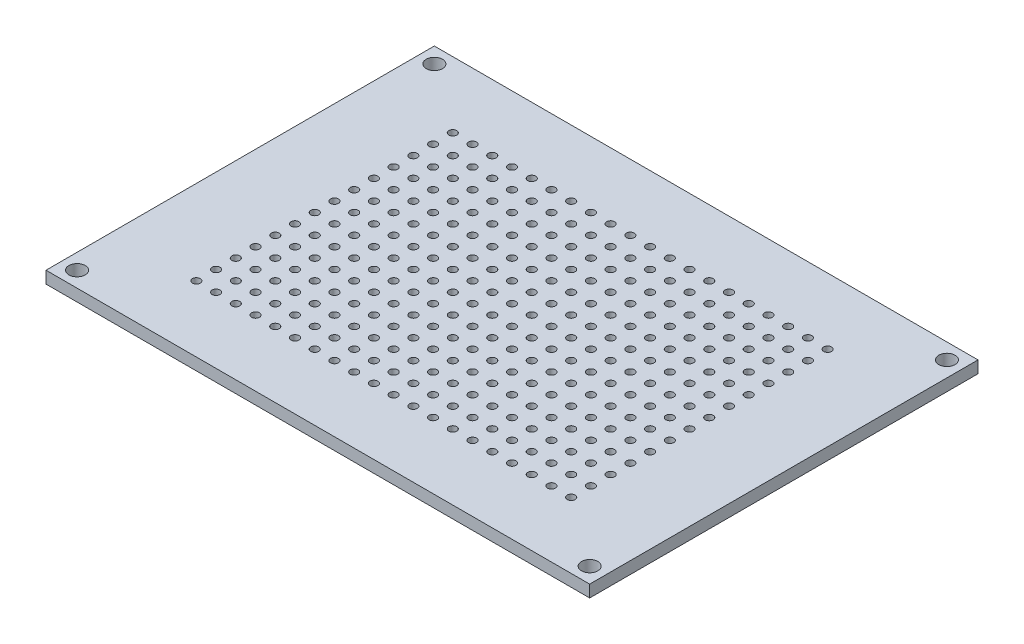
from build123d import *

# Parameters (mm, degrees)
SKETCH1_W           = 70
SKETCH1_H           = 50
SKETCH1_R           = 0.508
SKETCH1_R_2         = 1.05
BOSS_EXTRUDE1_DEPTH = 1.55


with BuildPart() as part:
    # Sketch1 → Boss-Extrude1 (new body)
    with BuildSketch(Plane(origin=(0, 0, 0), x_dir=(1, 0, 0), z_dir=(0, 1, 0))):
        with Locations((35, 25)):
            Rectangle(SKETCH1_W, SKETCH1_H)
        with Locations((33.73, 23.73)):
            Circle(SKETCH1_R, mode=Mode.SUBTRACT)
        with Locations((36.27, 23.73)):
            Circle(SKETCH1_R, mode=Mode.SUBTRACT)
        with Locations((38.81, 23.73)):
            Circle(SKETCH1_R, mode=Mode.SUBTRACT)
        with Locations((41.35, 23.73)):
            Circle(SKETCH1_R, mode=Mode.SUBTRACT)
        with Locations((43.89, 23.73)):
            Circle(SKETCH1_R, mode=Mode.SUBTRACT)
        with Locations((46.43, 23.73)):
            Circle(SKETCH1_R, mode=Mode.SUBTRACT)
        with Locations((48.97, 23.73)):
            Circle(SKETCH1_R, mode=Mode.SUBTRACT)
        with Locations((51.51, 23.73)):
            Circle(SKETCH1_R, mode=Mode.SUBTRACT)
        with Locations((54.05, 23.73)):
            Circle(SKETCH1_R, mode=Mode.SUBTRACT)
        with Locations((56.59, 23.73)):
            Circle(SKETCH1_R, mode=Mode.SUBTRACT)
        with Locations((59.13, 23.73)):
            Circle(SKETCH1_R, mode=Mode.SUBTRACT)
        with Locations((36.27, 26.27)):
            Circle(SKETCH1_R, mode=Mode.SUBTRACT)
        with Locations((38.81, 26.27)):
            Circle(SKETCH1_R, mode=Mode.SUBTRACT)
        with Locations((41.35, 26.27)):
            Circle(SKETCH1_R, mode=Mode.SUBTRACT)
        with Locations((43.89, 26.27)):
            Circle(SKETCH1_R, mode=Mode.SUBTRACT)
        with Locations((46.43, 26.27)):
            Circle(SKETCH1_R, mode=Mode.SUBTRACT)
        with Locations((48.97, 26.27)):
            Circle(SKETCH1_R, mode=Mode.SUBTRACT)
        with Locations((51.51, 26.27)):
            Circle(SKETCH1_R, mode=Mode.SUBTRACT)
        with Locations((54.05, 26.27)):
            Circle(SKETCH1_R, mode=Mode.SUBTRACT)
        with Locations((56.59, 26.27)):
            Circle(SKETCH1_R, mode=Mode.SUBTRACT)
        with Locations((59.13, 26.27)):
            Circle(SKETCH1_R, mode=Mode.SUBTRACT)
        with Locations((36.27, 28.81)):
            Circle(SKETCH1_R, mode=Mode.SUBTRACT)
        with Locations((38.81, 28.81)):
            Circle(SKETCH1_R, mode=Mode.SUBTRACT)
        with Locations((41.35, 28.81)):
            Circle(SKETCH1_R, mode=Mode.SUBTRACT)
        with Locations((43.89, 28.81)):
            Circle(SKETCH1_R, mode=Mode.SUBTRACT)
        with Locations((46.43, 28.81)):
            Circle(SKETCH1_R, mode=Mode.SUBTRACT)
        with Locations((48.97, 28.81)):
            Circle(SKETCH1_R, mode=Mode.SUBTRACT)
        with Locations((51.51, 28.81)):
            Circle(SKETCH1_R, mode=Mode.SUBTRACT)
        with Locations((54.05, 28.81)):
            Circle(SKETCH1_R, mode=Mode.SUBTRACT)
        with Locations((56.59, 28.81)):
            Circle(SKETCH1_R, mode=Mode.SUBTRACT)
        with Locations((59.13, 28.81)):
            Circle(SKETCH1_R, mode=Mode.SUBTRACT)
        with Locations((36.27, 31.35)):
            Circle(SKETCH1_R, mode=Mode.SUBTRACT)
        with Locations((38.81, 31.35)):
            Circle(SKETCH1_R, mode=Mode.SUBTRACT)
        with Locations((41.35, 31.35)):
            Circle(SKETCH1_R, mode=Mode.SUBTRACT)
        with Locations((43.89, 31.35)):
            Circle(SKETCH1_R, mode=Mode.SUBTRACT)
        with Locations((46.43, 31.35)):
            Circle(SKETCH1_R, mode=Mode.SUBTRACT)
        with Locations((48.97, 31.35)):
            Circle(SKETCH1_R, mode=Mode.SUBTRACT)
        with Locations((51.51, 31.35)):
            Circle(SKETCH1_R, mode=Mode.SUBTRACT)
        with Locations((54.05, 31.35)):
            Circle(SKETCH1_R, mode=Mode.SUBTRACT)
        with Locations((56.59, 31.35)):
            Circle(SKETCH1_R, mode=Mode.SUBTRACT)
        with Locations((59.13, 31.35)):
            Circle(SKETCH1_R, mode=Mode.SUBTRACT)
        with Locations((36.27, 33.89)):
            Circle(SKETCH1_R, mode=Mode.SUBTRACT)
        with Locations((38.81, 33.89)):
            Circle(SKETCH1_R, mode=Mode.SUBTRACT)
        with Locations((41.35, 33.89)):
            Circle(SKETCH1_R, mode=Mode.SUBTRACT)
        with Locations((43.89, 33.89)):
            Circle(SKETCH1_R, mode=Mode.SUBTRACT)
        with Locations((46.43, 33.89)):
            Circle(SKETCH1_R, mode=Mode.SUBTRACT)
        with Locations((48.97, 33.89)):
            Circle(SKETCH1_R, mode=Mode.SUBTRACT)
        with Locations((51.51, 33.89)):
            Circle(SKETCH1_R, mode=Mode.SUBTRACT)
        with Locations((54.05, 33.89)):
            Circle(SKETCH1_R, mode=Mode.SUBTRACT)
        with Locations((56.59, 33.89)):
            Circle(SKETCH1_R, mode=Mode.SUBTRACT)
        with Locations((59.13, 33.89)):
            Circle(SKETCH1_R, mode=Mode.SUBTRACT)
        with Locations((36.27, 36.43)):
            Circle(SKETCH1_R, mode=Mode.SUBTRACT)
        with Locations((38.81, 36.43)):
            Circle(SKETCH1_R, mode=Mode.SUBTRACT)
        with Locations((41.35, 36.43)):
            Circle(SKETCH1_R, mode=Mode.SUBTRACT)
        with Locations((43.89, 36.43)):
            Circle(SKETCH1_R, mode=Mode.SUBTRACT)
        with Locations((46.43, 36.43)):
            Circle(SKETCH1_R, mode=Mode.SUBTRACT)
        with Locations((48.97, 36.43)):
            Circle(SKETCH1_R, mode=Mode.SUBTRACT)
        with Locations((51.51, 36.43)):
            Circle(SKETCH1_R, mode=Mode.SUBTRACT)
        with Locations((54.05, 36.43)):
            Circle(SKETCH1_R, mode=Mode.SUBTRACT)
        with Locations((56.59, 36.43)):
            Circle(SKETCH1_R, mode=Mode.SUBTRACT)
        with Locations((59.13, 36.43)):
            Circle(SKETCH1_R, mode=Mode.SUBTRACT)
        with Locations((36.27, 38.97)):
            Circle(SKETCH1_R, mode=Mode.SUBTRACT)
        with Locations((38.81, 38.97)):
            Circle(SKETCH1_R, mode=Mode.SUBTRACT)
        with Locations((41.35, 38.97)):
            Circle(SKETCH1_R, mode=Mode.SUBTRACT)
        with Locations((43.89, 38.97)):
            Circle(SKETCH1_R, mode=Mode.SUBTRACT)
        with Locations((46.43, 38.97)):
            Circle(SKETCH1_R, mode=Mode.SUBTRACT)
        with Locations((48.97, 38.97)):
            Circle(SKETCH1_R, mode=Mode.SUBTRACT)
        with Locations((51.51, 38.97)):
            Circle(SKETCH1_R, mode=Mode.SUBTRACT)
        with Locations((54.05, 38.97)):
            Circle(SKETCH1_R, mode=Mode.SUBTRACT)
        with Locations((56.59, 38.97)):
            Circle(SKETCH1_R, mode=Mode.SUBTRACT)
        with Locations((59.13, 38.97)):
            Circle(SKETCH1_R, mode=Mode.SUBTRACT)
        with Locations((36.27, 41.51)):
            Circle(SKETCH1_R, mode=Mode.SUBTRACT)
        with Locations((38.81, 41.51)):
            Circle(SKETCH1_R, mode=Mode.SUBTRACT)
        with Locations((41.35, 41.51)):
            Circle(SKETCH1_R, mode=Mode.SUBTRACT)
        with Locations((43.89, 41.51)):
            Circle(SKETCH1_R, mode=Mode.SUBTRACT)
        with Locations((46.43, 41.51)):
            Circle(SKETCH1_R, mode=Mode.SUBTRACT)
        with Locations((48.97, 41.51)):
            Circle(SKETCH1_R, mode=Mode.SUBTRACT)
        with Locations((51.51, 41.51)):
            Circle(SKETCH1_R, mode=Mode.SUBTRACT)
        with Locations((54.05, 41.51)):
            Circle(SKETCH1_R, mode=Mode.SUBTRACT)
        with Locations((56.59, 41.51)):
            Circle(SKETCH1_R, mode=Mode.SUBTRACT)
        with Locations((59.13, 41.51)):
            Circle(SKETCH1_R, mode=Mode.SUBTRACT)
        with Locations((33.73, 26.27)):
            Circle(SKETCH1_R, mode=Mode.SUBTRACT)
        with Locations((33.73, 28.81)):
            Circle(SKETCH1_R, mode=Mode.SUBTRACT)
        with Locations((33.73, 31.35)):
            Circle(SKETCH1_R, mode=Mode.SUBTRACT)
        with Locations((33.73, 33.89)):
            Circle(SKETCH1_R, mode=Mode.SUBTRACT)
        with Locations((33.73, 36.43)):
            Circle(SKETCH1_R, mode=Mode.SUBTRACT)
        with Locations((33.73, 38.97)):
            Circle(SKETCH1_R, mode=Mode.SUBTRACT)
        with Locations((33.73, 41.51)):
            Circle(SKETCH1_R, mode=Mode.SUBTRACT)
        with Locations((31.19, 41.51)):
            Circle(SKETCH1_R, mode=Mode.SUBTRACT)
        with Locations((28.65, 41.51)):
            Circle(SKETCH1_R, mode=Mode.SUBTRACT)
        with Locations((26.11, 41.51)):
            Circle(SKETCH1_R, mode=Mode.SUBTRACT)
        with Locations((23.57, 41.51)):
            Circle(SKETCH1_R, mode=Mode.SUBTRACT)
        with Locations((21.03, 41.51)):
            Circle(SKETCH1_R, mode=Mode.SUBTRACT)
        with Locations((18.49, 41.51)):
            Circle(SKETCH1_R, mode=Mode.SUBTRACT)
        with Locations((15.95, 41.51)):
            Circle(SKETCH1_R, mode=Mode.SUBTRACT)
        with Locations((13.41, 41.51)):
            Circle(SKETCH1_R, mode=Mode.SUBTRACT)
        with Locations((10.87, 41.51)):
            Circle(SKETCH1_R, mode=Mode.SUBTRACT)
        with Locations((31.19, 38.97)):
            Circle(SKETCH1_R, mode=Mode.SUBTRACT)
        with Locations((28.65, 38.97)):
            Circle(SKETCH1_R, mode=Mode.SUBTRACT)
        with Locations((26.11, 38.97)):
            Circle(SKETCH1_R, mode=Mode.SUBTRACT)
        with Locations((23.57, 38.97)):
            Circle(SKETCH1_R, mode=Mode.SUBTRACT)
        with Locations((21.03, 38.97)):
            Circle(SKETCH1_R, mode=Mode.SUBTRACT)
        with Locations((18.49, 38.97)):
            Circle(SKETCH1_R, mode=Mode.SUBTRACT)
        with Locations((15.95, 38.97)):
            Circle(SKETCH1_R, mode=Mode.SUBTRACT)
        with Locations((13.41, 38.97)):
            Circle(SKETCH1_R, mode=Mode.SUBTRACT)
        with Locations((10.87, 38.97)):
            Circle(SKETCH1_R, mode=Mode.SUBTRACT)
        with Locations((31.19, 36.43)):
            Circle(SKETCH1_R, mode=Mode.SUBTRACT)
        with Locations((28.65, 36.43)):
            Circle(SKETCH1_R, mode=Mode.SUBTRACT)
        with Locations((26.11, 36.43)):
            Circle(SKETCH1_R, mode=Mode.SUBTRACT)
        with Locations((23.57, 36.43)):
            Circle(SKETCH1_R, mode=Mode.SUBTRACT)
        with Locations((21.03, 36.43)):
            Circle(SKETCH1_R, mode=Mode.SUBTRACT)
        with Locations((18.49, 36.43)):
            Circle(SKETCH1_R, mode=Mode.SUBTRACT)
        with Locations((15.95, 36.43)):
            Circle(SKETCH1_R, mode=Mode.SUBTRACT)
        with Locations((13.41, 36.43)):
            Circle(SKETCH1_R, mode=Mode.SUBTRACT)
        with Locations((10.87, 36.43)):
            Circle(SKETCH1_R, mode=Mode.SUBTRACT)
        with Locations((31.19, 33.89)):
            Circle(SKETCH1_R, mode=Mode.SUBTRACT)
        with Locations((28.65, 33.89)):
            Circle(SKETCH1_R, mode=Mode.SUBTRACT)
        with Locations((26.11, 33.89)):
            Circle(SKETCH1_R, mode=Mode.SUBTRACT)
        with Locations((23.57, 33.89)):
            Circle(SKETCH1_R, mode=Mode.SUBTRACT)
        with Locations((21.03, 33.89)):
            Circle(SKETCH1_R, mode=Mode.SUBTRACT)
        with Locations((18.49, 33.89)):
            Circle(SKETCH1_R, mode=Mode.SUBTRACT)
        with Locations((15.95, 33.89)):
            Circle(SKETCH1_R, mode=Mode.SUBTRACT)
        with Locations((13.41, 33.89)):
            Circle(SKETCH1_R, mode=Mode.SUBTRACT)
        with Locations((10.87, 33.89)):
            Circle(SKETCH1_R, mode=Mode.SUBTRACT)
        with Locations((31.19, 31.35)):
            Circle(SKETCH1_R, mode=Mode.SUBTRACT)
        with Locations((28.65, 31.35)):
            Circle(SKETCH1_R, mode=Mode.SUBTRACT)
        with Locations((26.11, 31.35)):
            Circle(SKETCH1_R, mode=Mode.SUBTRACT)
        with Locations((23.57, 31.35)):
            Circle(SKETCH1_R, mode=Mode.SUBTRACT)
        with Locations((21.03, 31.35)):
            Circle(SKETCH1_R, mode=Mode.SUBTRACT)
        with Locations((18.49, 31.35)):
            Circle(SKETCH1_R, mode=Mode.SUBTRACT)
        with Locations((15.95, 31.35)):
            Circle(SKETCH1_R, mode=Mode.SUBTRACT)
        with Locations((13.41, 31.35)):
            Circle(SKETCH1_R, mode=Mode.SUBTRACT)
        with Locations((10.87, 31.35)):
            Circle(SKETCH1_R, mode=Mode.SUBTRACT)
        with Locations((31.19, 28.81)):
            Circle(SKETCH1_R, mode=Mode.SUBTRACT)
        with Locations((28.65, 28.81)):
            Circle(SKETCH1_R, mode=Mode.SUBTRACT)
        with Locations((26.11, 28.81)):
            Circle(SKETCH1_R, mode=Mode.SUBTRACT)
        with Locations((23.57, 28.81)):
            Circle(SKETCH1_R, mode=Mode.SUBTRACT)
        with Locations((21.03, 28.81)):
            Circle(SKETCH1_R, mode=Mode.SUBTRACT)
        with Locations((18.49, 28.81)):
            Circle(SKETCH1_R, mode=Mode.SUBTRACT)
        with Locations((15.95, 28.81)):
            Circle(SKETCH1_R, mode=Mode.SUBTRACT)
        with Locations((13.41, 28.81)):
            Circle(SKETCH1_R, mode=Mode.SUBTRACT)
        with Locations((10.87, 28.81)):
            Circle(SKETCH1_R, mode=Mode.SUBTRACT)
        with Locations((31.19, 26.27)):
            Circle(SKETCH1_R, mode=Mode.SUBTRACT)
        with Locations((28.65, 26.27)):
            Circle(SKETCH1_R, mode=Mode.SUBTRACT)
        with Locations((26.11, 26.27)):
            Circle(SKETCH1_R, mode=Mode.SUBTRACT)
        with Locations((23.57, 26.27)):
            Circle(SKETCH1_R, mode=Mode.SUBTRACT)
        with Locations((21.03, 26.27)):
            Circle(SKETCH1_R, mode=Mode.SUBTRACT)
        with Locations((18.49, 26.27)):
            Circle(SKETCH1_R, mode=Mode.SUBTRACT)
        with Locations((15.95, 26.27)):
            Circle(SKETCH1_R, mode=Mode.SUBTRACT)
        with Locations((13.41, 26.27)):
            Circle(SKETCH1_R, mode=Mode.SUBTRACT)
        with Locations((10.87, 26.27)):
            Circle(SKETCH1_R, mode=Mode.SUBTRACT)
        with Locations((31.19, 23.73)):
            Circle(SKETCH1_R, mode=Mode.SUBTRACT)
        with Locations((28.65, 23.73)):
            Circle(SKETCH1_R, mode=Mode.SUBTRACT)
        with Locations((26.11, 23.73)):
            Circle(SKETCH1_R, mode=Mode.SUBTRACT)
        with Locations((23.57, 23.73)):
            Circle(SKETCH1_R, mode=Mode.SUBTRACT)
        with Locations((21.03, 23.73)):
            Circle(SKETCH1_R, mode=Mode.SUBTRACT)
        with Locations((18.49, 23.73)):
            Circle(SKETCH1_R, mode=Mode.SUBTRACT)
        with Locations((15.95, 23.73)):
            Circle(SKETCH1_R, mode=Mode.SUBTRACT)
        with Locations((13.41, 23.73)):
            Circle(SKETCH1_R, mode=Mode.SUBTRACT)
        with Locations((10.87, 23.73)):
            Circle(SKETCH1_R, mode=Mode.SUBTRACT)
        with Locations((56.59, 21.19)):
            Circle(SKETCH1_R, mode=Mode.SUBTRACT)
        with Locations((54.05, 21.19)):
            Circle(SKETCH1_R, mode=Mode.SUBTRACT)
        with Locations((51.51, 21.19)):
            Circle(SKETCH1_R, mode=Mode.SUBTRACT)
        with Locations((48.97, 21.19)):
            Circle(SKETCH1_R, mode=Mode.SUBTRACT)
        with Locations((46.43, 21.19)):
            Circle(SKETCH1_R, mode=Mode.SUBTRACT)
        with Locations((43.89, 21.19)):
            Circle(SKETCH1_R, mode=Mode.SUBTRACT)
        with Locations((41.35, 21.19)):
            Circle(SKETCH1_R, mode=Mode.SUBTRACT)
        with Locations((38.81, 21.19)):
            Circle(SKETCH1_R, mode=Mode.SUBTRACT)
        with Locations((36.27, 21.19)):
            Circle(SKETCH1_R, mode=Mode.SUBTRACT)
        with Locations((33.73, 21.19)):
            Circle(SKETCH1_R, mode=Mode.SUBTRACT)
        with Locations((31.19, 21.19)):
            Circle(SKETCH1_R, mode=Mode.SUBTRACT)
        with Locations((28.65, 21.19)):
            Circle(SKETCH1_R, mode=Mode.SUBTRACT)
        with Locations((26.11, 21.19)):
            Circle(SKETCH1_R, mode=Mode.SUBTRACT)
        with Locations((23.57, 21.19)):
            Circle(SKETCH1_R, mode=Mode.SUBTRACT)
        with Locations((21.03, 21.19)):
            Circle(SKETCH1_R, mode=Mode.SUBTRACT)
        with Locations((18.49, 21.19)):
            Circle(SKETCH1_R, mode=Mode.SUBTRACT)
        with Locations((15.95, 21.19)):
            Circle(SKETCH1_R, mode=Mode.SUBTRACT)
        with Locations((13.41, 21.19)):
            Circle(SKETCH1_R, mode=Mode.SUBTRACT)
        with Locations((10.87, 21.19)):
            Circle(SKETCH1_R, mode=Mode.SUBTRACT)
        with Locations((56.59, 18.65)):
            Circle(SKETCH1_R, mode=Mode.SUBTRACT)
        with Locations((54.05, 18.65)):
            Circle(SKETCH1_R, mode=Mode.SUBTRACT)
        with Locations((51.51, 18.65)):
            Circle(SKETCH1_R, mode=Mode.SUBTRACT)
        with Locations((48.97, 18.65)):
            Circle(SKETCH1_R, mode=Mode.SUBTRACT)
        with Locations((46.43, 18.65)):
            Circle(SKETCH1_R, mode=Mode.SUBTRACT)
        with Locations((43.89, 18.65)):
            Circle(SKETCH1_R, mode=Mode.SUBTRACT)
        with Locations((41.35, 18.65)):
            Circle(SKETCH1_R, mode=Mode.SUBTRACT)
        with Locations((38.81, 18.65)):
            Circle(SKETCH1_R, mode=Mode.SUBTRACT)
        with Locations((36.27, 18.65)):
            Circle(SKETCH1_R, mode=Mode.SUBTRACT)
        with Locations((33.73, 18.65)):
            Circle(SKETCH1_R, mode=Mode.SUBTRACT)
        with Locations((31.19, 18.65)):
            Circle(SKETCH1_R, mode=Mode.SUBTRACT)
        with Locations((28.65, 18.65)):
            Circle(SKETCH1_R, mode=Mode.SUBTRACT)
        with Locations((26.11, 18.65)):
            Circle(SKETCH1_R, mode=Mode.SUBTRACT)
        with Locations((23.57, 18.65)):
            Circle(SKETCH1_R, mode=Mode.SUBTRACT)
        with Locations((21.03, 18.65)):
            Circle(SKETCH1_R, mode=Mode.SUBTRACT)
        with Locations((18.49, 18.65)):
            Circle(SKETCH1_R, mode=Mode.SUBTRACT)
        with Locations((15.95, 18.65)):
            Circle(SKETCH1_R, mode=Mode.SUBTRACT)
        with Locations((13.41, 18.65)):
            Circle(SKETCH1_R, mode=Mode.SUBTRACT)
        with Locations((10.87, 18.65)):
            Circle(SKETCH1_R, mode=Mode.SUBTRACT)
        with Locations((56.59, 16.11)):
            Circle(SKETCH1_R, mode=Mode.SUBTRACT)
        with Locations((54.05, 16.11)):
            Circle(SKETCH1_R, mode=Mode.SUBTRACT)
        with Locations((51.51, 16.11)):
            Circle(SKETCH1_R, mode=Mode.SUBTRACT)
        with Locations((48.97, 16.11)):
            Circle(SKETCH1_R, mode=Mode.SUBTRACT)
        with Locations((46.43, 16.11)):
            Circle(SKETCH1_R, mode=Mode.SUBTRACT)
        with Locations((43.89, 16.11)):
            Circle(SKETCH1_R, mode=Mode.SUBTRACT)
        with Locations((41.35, 16.11)):
            Circle(SKETCH1_R, mode=Mode.SUBTRACT)
        with Locations((38.81, 16.11)):
            Circle(SKETCH1_R, mode=Mode.SUBTRACT)
        with Locations((36.27, 16.11)):
            Circle(SKETCH1_R, mode=Mode.SUBTRACT)
        with Locations((33.73, 16.11)):
            Circle(SKETCH1_R, mode=Mode.SUBTRACT)
        with Locations((31.19, 16.11)):
            Circle(SKETCH1_R, mode=Mode.SUBTRACT)
        with Locations((28.65, 16.11)):
            Circle(SKETCH1_R, mode=Mode.SUBTRACT)
        with Locations((26.11, 16.11)):
            Circle(SKETCH1_R, mode=Mode.SUBTRACT)
        with Locations((23.57, 16.11)):
            Circle(SKETCH1_R, mode=Mode.SUBTRACT)
        with Locations((21.03, 16.11)):
            Circle(SKETCH1_R, mode=Mode.SUBTRACT)
        with Locations((18.49, 16.11)):
            Circle(SKETCH1_R, mode=Mode.SUBTRACT)
        with Locations((15.95, 16.11)):
            Circle(SKETCH1_R, mode=Mode.SUBTRACT)
        with Locations((13.41, 16.11)):
            Circle(SKETCH1_R, mode=Mode.SUBTRACT)
        with Locations((10.87, 16.11)):
            Circle(SKETCH1_R, mode=Mode.SUBTRACT)
        with Locations((56.59, 13.57)):
            Circle(SKETCH1_R, mode=Mode.SUBTRACT)
        with Locations((54.05, 13.57)):
            Circle(SKETCH1_R, mode=Mode.SUBTRACT)
        with Locations((51.51, 13.57)):
            Circle(SKETCH1_R, mode=Mode.SUBTRACT)
        with Locations((48.97, 13.57)):
            Circle(SKETCH1_R, mode=Mode.SUBTRACT)
        with Locations((46.43, 13.57)):
            Circle(SKETCH1_R, mode=Mode.SUBTRACT)
        with Locations((43.89, 13.57)):
            Circle(SKETCH1_R, mode=Mode.SUBTRACT)
        with Locations((41.35, 13.57)):
            Circle(SKETCH1_R, mode=Mode.SUBTRACT)
        with Locations((38.81, 13.57)):
            Circle(SKETCH1_R, mode=Mode.SUBTRACT)
        with Locations((36.27, 13.57)):
            Circle(SKETCH1_R, mode=Mode.SUBTRACT)
        with Locations((33.73, 13.57)):
            Circle(SKETCH1_R, mode=Mode.SUBTRACT)
        with Locations((31.19, 13.57)):
            Circle(SKETCH1_R, mode=Mode.SUBTRACT)
        with Locations((28.65, 13.57)):
            Circle(SKETCH1_R, mode=Mode.SUBTRACT)
        with Locations((26.11, 13.57)):
            Circle(SKETCH1_R, mode=Mode.SUBTRACT)
        with Locations((23.57, 13.57)):
            Circle(SKETCH1_R, mode=Mode.SUBTRACT)
        with Locations((21.03, 13.57)):
            Circle(SKETCH1_R, mode=Mode.SUBTRACT)
        with Locations((18.49, 13.57)):
            Circle(SKETCH1_R, mode=Mode.SUBTRACT)
        with Locations((15.95, 13.57)):
            Circle(SKETCH1_R, mode=Mode.SUBTRACT)
        with Locations((13.41, 13.57)):
            Circle(SKETCH1_R, mode=Mode.SUBTRACT)
        with Locations((10.87, 13.57)):
            Circle(SKETCH1_R, mode=Mode.SUBTRACT)
        with Locations((56.59, 11.03)):
            Circle(SKETCH1_R, mode=Mode.SUBTRACT)
        with Locations((54.05, 11.03)):
            Circle(SKETCH1_R, mode=Mode.SUBTRACT)
        with Locations((51.51, 11.03)):
            Circle(SKETCH1_R, mode=Mode.SUBTRACT)
        with Locations((48.97, 11.03)):
            Circle(SKETCH1_R, mode=Mode.SUBTRACT)
        with Locations((46.43, 11.03)):
            Circle(SKETCH1_R, mode=Mode.SUBTRACT)
        with Locations((43.89, 11.03)):
            Circle(SKETCH1_R, mode=Mode.SUBTRACT)
        with Locations((41.35, 11.03)):
            Circle(SKETCH1_R, mode=Mode.SUBTRACT)
        with Locations((38.81, 11.03)):
            Circle(SKETCH1_R, mode=Mode.SUBTRACT)
        with Locations((36.27, 11.03)):
            Circle(SKETCH1_R, mode=Mode.SUBTRACT)
        with Locations((33.73, 11.03)):
            Circle(SKETCH1_R, mode=Mode.SUBTRACT)
        with Locations((31.19, 11.03)):
            Circle(SKETCH1_R, mode=Mode.SUBTRACT)
        with Locations((28.65, 11.03)):
            Circle(SKETCH1_R, mode=Mode.SUBTRACT)
        with Locations((26.11, 11.03)):
            Circle(SKETCH1_R, mode=Mode.SUBTRACT)
        with Locations((23.57, 11.03)):
            Circle(SKETCH1_R, mode=Mode.SUBTRACT)
        with Locations((21.03, 11.03)):
            Circle(SKETCH1_R, mode=Mode.SUBTRACT)
        with Locations((18.49, 11.03)):
            Circle(SKETCH1_R, mode=Mode.SUBTRACT)
        with Locations((15.95, 11.03)):
            Circle(SKETCH1_R, mode=Mode.SUBTRACT)
        with Locations((13.41, 11.03)):
            Circle(SKETCH1_R, mode=Mode.SUBTRACT)
        with Locations((10.87, 11.03)):
            Circle(SKETCH1_R, mode=Mode.SUBTRACT)
        with Locations((56.59, 8.49)):
            Circle(SKETCH1_R, mode=Mode.SUBTRACT)
        with Locations((54.05, 8.49)):
            Circle(SKETCH1_R, mode=Mode.SUBTRACT)
        with Locations((51.51, 8.49)):
            Circle(SKETCH1_R, mode=Mode.SUBTRACT)
        with Locations((48.97, 8.49)):
            Circle(SKETCH1_R, mode=Mode.SUBTRACT)
        with Locations((46.43, 8.49)):
            Circle(SKETCH1_R, mode=Mode.SUBTRACT)
        with Locations((43.89, 8.49)):
            Circle(SKETCH1_R, mode=Mode.SUBTRACT)
        with Locations((41.35, 8.49)):
            Circle(SKETCH1_R, mode=Mode.SUBTRACT)
        with Locations((38.81, 8.49)):
            Circle(SKETCH1_R, mode=Mode.SUBTRACT)
        with Locations((36.27, 8.49)):
            Circle(SKETCH1_R, mode=Mode.SUBTRACT)
        with Locations((33.73, 8.49)):
            Circle(SKETCH1_R, mode=Mode.SUBTRACT)
        with Locations((31.19, 8.49)):
            Circle(SKETCH1_R, mode=Mode.SUBTRACT)
        with Locations((28.65, 8.49)):
            Circle(SKETCH1_R, mode=Mode.SUBTRACT)
        with Locations((26.11, 8.49)):
            Circle(SKETCH1_R, mode=Mode.SUBTRACT)
        with Locations((23.57, 8.49)):
            Circle(SKETCH1_R, mode=Mode.SUBTRACT)
        with Locations((21.03, 8.49)):
            Circle(SKETCH1_R, mode=Mode.SUBTRACT)
        with Locations((18.49, 8.49)):
            Circle(SKETCH1_R, mode=Mode.SUBTRACT)
        with Locations((15.95, 8.49)):
            Circle(SKETCH1_R, mode=Mode.SUBTRACT)
        with Locations((13.41, 8.49)):
            Circle(SKETCH1_R, mode=Mode.SUBTRACT)
        with Locations((10.87, 8.49)):
            Circle(SKETCH1_R, mode=Mode.SUBTRACT)
        with Locations((59.13, 21.19)):
            Circle(SKETCH1_R, mode=Mode.SUBTRACT)
        with Locations((59.13, 18.65)):
            Circle(SKETCH1_R, mode=Mode.SUBTRACT)
        with Locations((59.13, 16.11)):
            Circle(SKETCH1_R, mode=Mode.SUBTRACT)
        with Locations((59.13, 13.57)):
            Circle(SKETCH1_R, mode=Mode.SUBTRACT)
        with Locations((59.13, 11.03)):
            Circle(SKETCH1_R, mode=Mode.SUBTRACT)
        with Locations((59.13, 8.49)):
            Circle(SKETCH1_R, mode=Mode.SUBTRACT)
        with Locations((2, 2)):
            Circle(SKETCH1_R_2, mode=Mode.SUBTRACT)
        with Locations((68, 2)):
            Circle(SKETCH1_R_2, mode=Mode.SUBTRACT)
        with Locations((68, 48)):
            Circle(SKETCH1_R_2, mode=Mode.SUBTRACT)
        with Locations((2, 48)):
            Circle(SKETCH1_R_2, mode=Mode.SUBTRACT)
    extrude(amount=BOSS_EXTRUDE1_DEPTH)


solid = part.part
